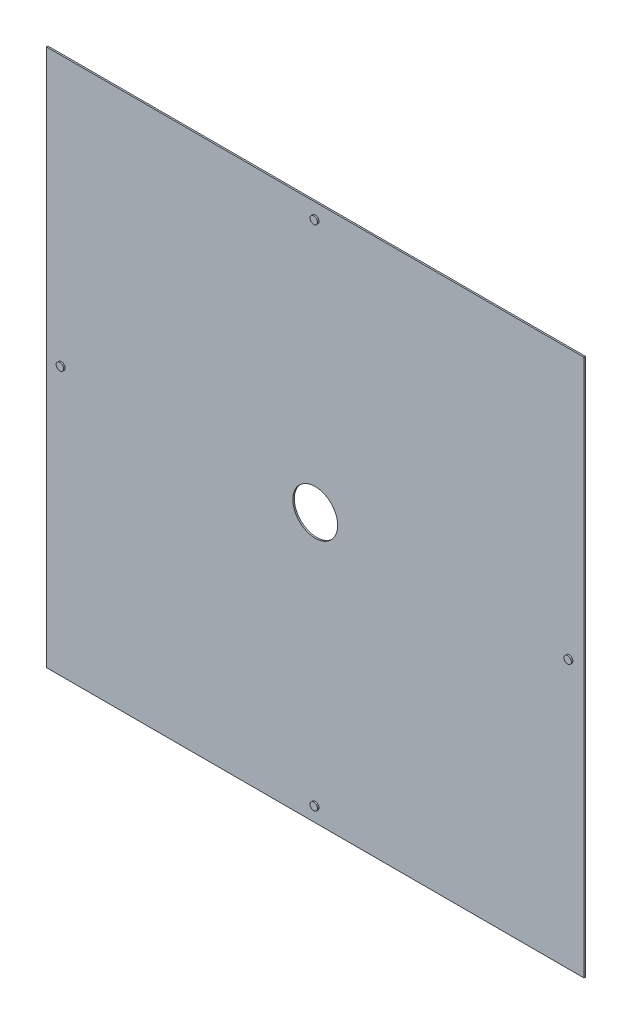
from build123d import *

# Parameters (mm, degrees)
SKETCH2_W           = 720
SKETCH2_H           = 720
SKETCH2_R           = 30
BOSS_EXTRUDE1_DEPTH = 2
SKETCH3_R           = 5
BOSS_EXTRUDE2_DEPTH = 2


with BuildPart() as part:
    # Sketch2 → Boss-Extrude1 (new body)
    with BuildSketch(Plane.XY):
        Rectangle(SKETCH2_W, SKETCH2_H)
        Circle(SKETCH2_R, mode=Mode.SUBTRACT)
    extrude(amount=BOSS_EXTRUDE1_DEPTH)

    # Sketch3 → Boss-Extrude2 (add)
    with BuildSketch(Plane.XY.offset(2)):
        with Locations((0, 340)):
            Circle(SKETCH3_R)
        with Locations((-340, 0)):
            Circle(SKETCH3_R)
        with Locations((0, -340)):
            Circle(SKETCH3_R)
        with Locations((340, 0)):
            Circle(SKETCH3_R)
    extrude(amount=BOSS_EXTRUDE2_DEPTH)


solid = part.part
